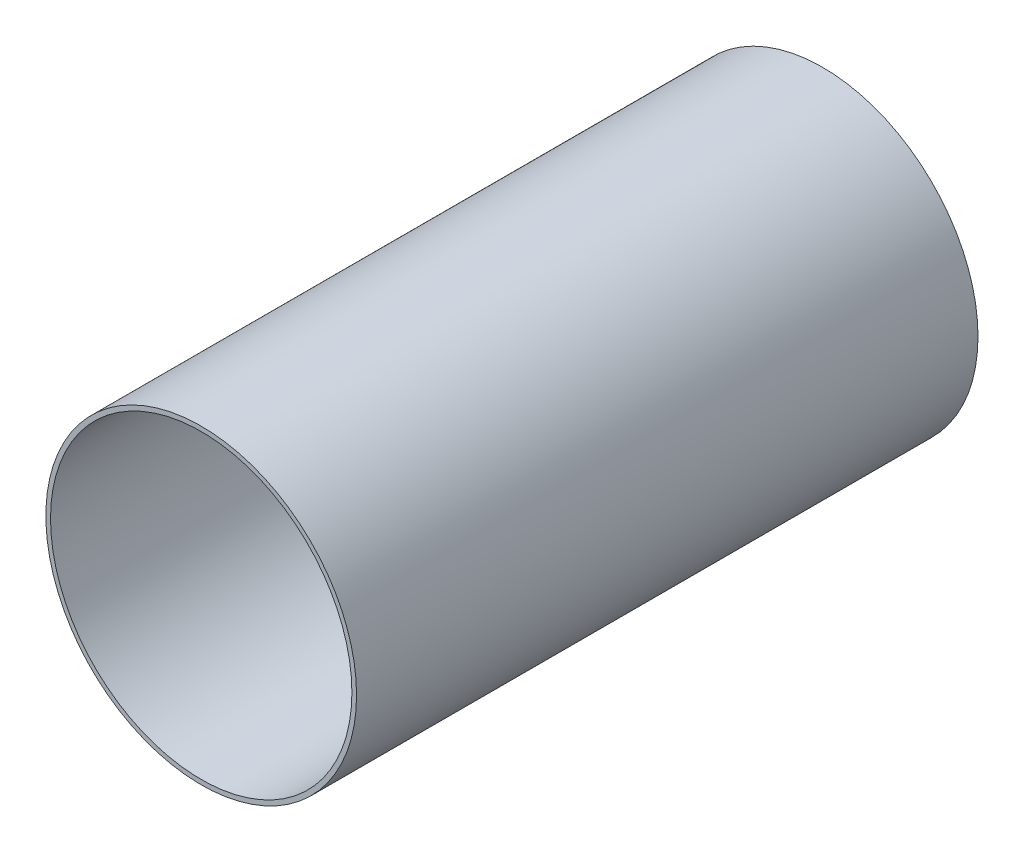
from build123d import *

# Parameters (mm, degrees)
SKETCH1_R           = 76.2
SKETCH1_R_2         = 73.914
BOSS_EXTRUDE1_DEPTH = 304.8


with BuildPart() as part:
    # Sketch1 → Boss-Extrude1 (new body)
    with BuildSketch(Plane.XY):
        Circle(SKETCH1_R)
        Circle(SKETCH1_R_2, mode=Mode.SUBTRACT)
    extrude(amount=BOSS_EXTRUDE1_DEPTH)


solid = part.part
